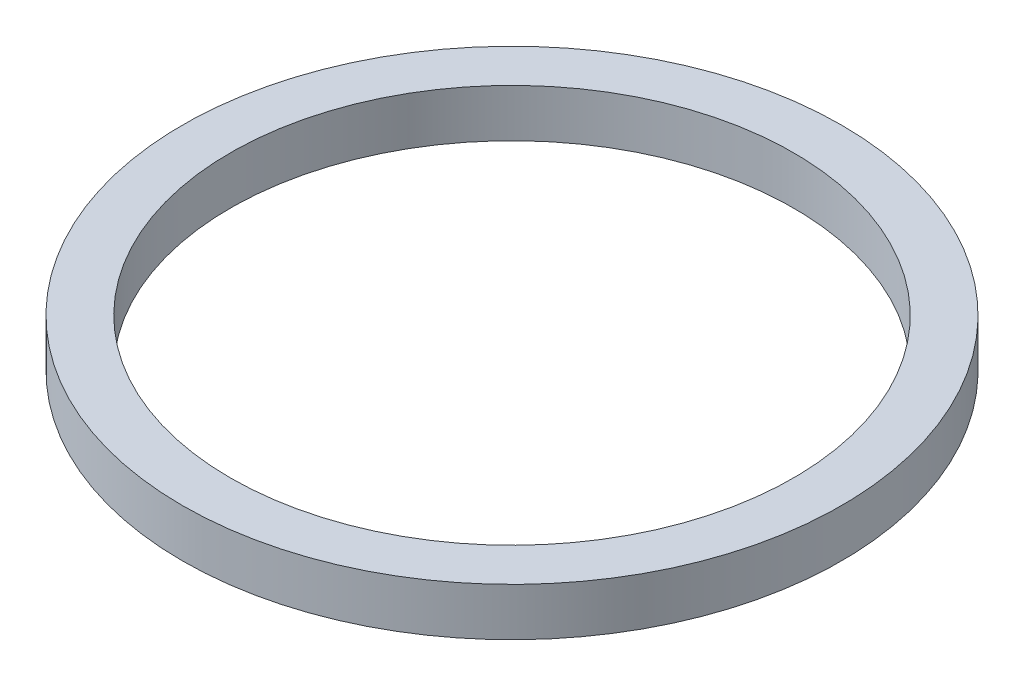
from build123d import *

# Parameters (mm, degrees)
SKETCH1_R           = 13.75
SKETCH1_R_2         = 11.75
BOSS_EXTRUDE1_DEPTH = 2


with BuildPart() as part:
    # Sketch1 → Boss-Extrude1 (new body)
    with BuildSketch(Plane(origin=(0, 0, 0), x_dir=(1, 0, 0), z_dir=(0, 1, 0))):
        Circle(SKETCH1_R)
        Circle(SKETCH1_R_2, mode=Mode.SUBTRACT)
    extrude(amount=BOSS_EXTRUDE1_DEPTH)


solid = part.part
